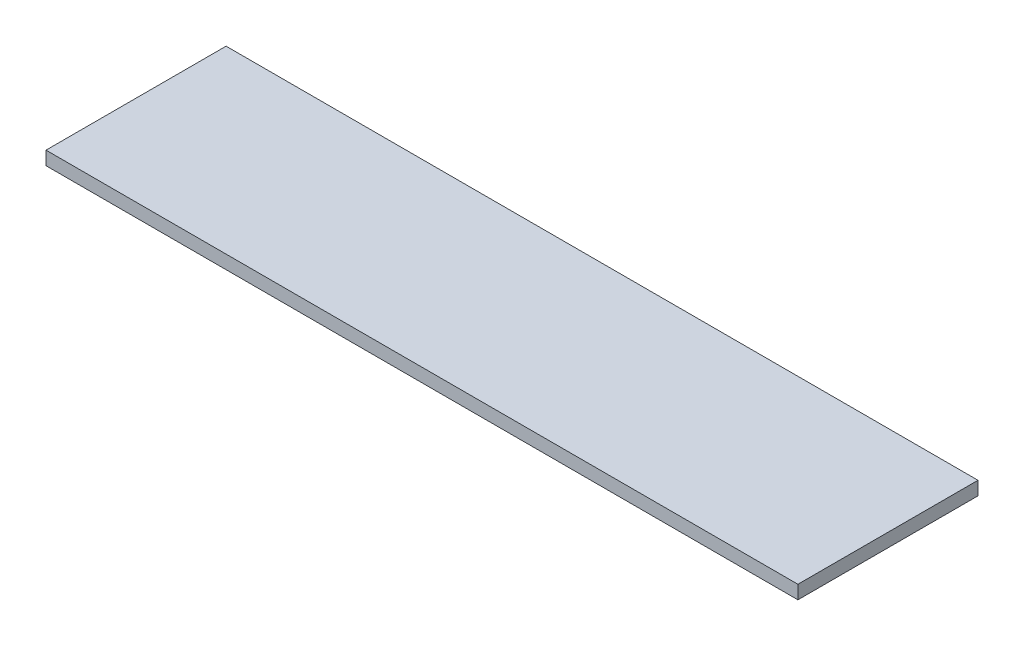
from build123d import *

# Parameters (mm, degrees)
SKETCH1_W           = 1060.45
SKETCH1_H           = 254
BOSS_EXTRUDE1_DEPTH = 19.05


with BuildPart() as part:
    # Sketch1 → Boss-Extrude1 (new body)
    with BuildSketch(Plane(origin=(0, 0, 0), x_dir=(1, 0, 0), z_dir=(0, 1, 0))):
        Rectangle(SKETCH1_W, SKETCH1_H)
    extrude(amount=BOSS_EXTRUDE1_DEPTH)


solid = part.part
